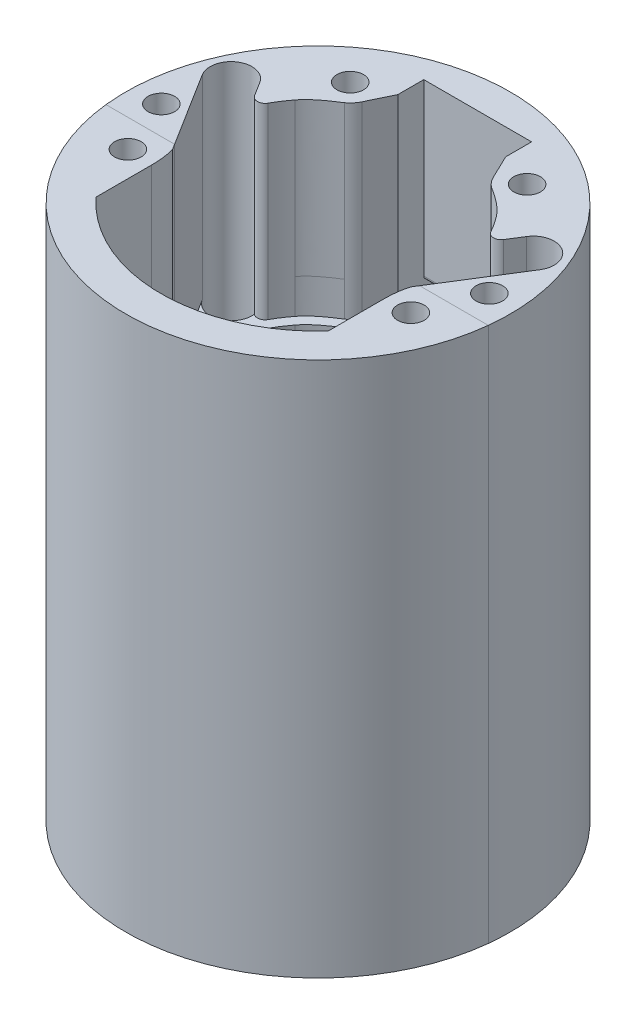
from build123d import *

# Parameters (mm, degrees)
SKETCH1_R              = 3.475
SKETCH1_R_2            = 5.461
BOSS_EXTRUDE2_DEPTH    = 100
SLOT_DEPTH             = 0.975
SKETCH2_W              = 28.2
SKETCH2_H              = 9.048762348
CUT_EXTRUDE1_DEPTH     = 3
FILLET1_R              = 1
LPATTERN1_COUNT        = 5
LPATTERN1_PITCH        = 20
FILLET1_OF_LPATTERN1_R = 1
SKETCH10_R             = 50.292
SKETCH10_R_2           = 3.475
SKETCH10_R_3           = 5.461
BOSS_EXTRUDE3_DEPTH    = 40
CUT_EXTRUDE2_START     = -50.975
CUT_EXTRUDE2_DEPTH     = 50.975
FILLET2_R              = 2


with BuildPart() as part:
    # Sketch1 → Boss-Extrude2 (new body)
    with BuildSketch(Plane(origin=(0, 0, 0), x_dir=(1, 0, 0), z_dir=(0, 1, 0))):
        with BuildLine():
            ThreePointArc((32.720459643, -38.19236553), (0, 50.292), (-32.720459643, -38.19236553))
            ThreePointArc((-32.720459643, -38.19236553), (0, -50.292), (32.720459643, -38.19236553))
        make_face()
        with Locations(Location((-37.000474826, -12.718618748, 0), (0, 0, 270))):
            Circle(SKETCH1_R, mode=Mode.SUBTRACT)
        with Locations(Location((-39.515350792, 16.778615909, 0), (0, 0, 270))):
            Circle(SKETCH1_R_2, mode=Mode.SUBTRACT)
        with Locations(Location((-23.129730363, 31.556520301, 0), (0, 0, 270))):
            Circle(SKETCH1_R, mode=Mode.SUBTRACT)
        with Locations(Location((37.000474826, -12.718618748, 0), (0, 0, 270))):
            Circle(SKETCH1_R, mode=Mode.SUBTRACT)
        with Locations(Location((39.515350792, 16.778615909, 0), (0, 0, 270))):
            Circle(SKETCH1_R_2, mode=Mode.SUBTRACT)
        with Locations(Location((23.129730363, 31.556520301, 0), (0, 0, 270))):
            Circle(SKETCH1_R, mode=Mode.SUBTRACT)
        with Locations(Location((-42.886820356, 1.924977859, 0), (0, 0, 270))):
            Circle(SKETCH1_R, mode=Mode.SUBTRACT)
        with Locations(Location((42.886820356, 1.924977859, 0), (0, 0, 270))):
            Circle(SKETCH1_R, mode=Mode.SUBTRACT)
        with BuildLine():
            Line((14.1, 34.984991814), (17.137442499, 28.672948531))
            ThreePointArc((17.137442499, 28.672948531), (18.015355552, 27.306147342), (19.198457256, 26.192977465))
            add(Edge.make_bspline(
                [(26.350445826, 20.302188629), (24.374677003, 22.988127573), (19.198457256, 26.192977465)],
                knots=[0, 0, 0, 1, 1, 1], degree=2))
            ThreePointArc((26.350445826, 20.302188629), (31.488556898, 10.723602139), (33.264468406, 0))
            add(Edge.make_bspline(
                [(30.348758021, -13.232808954), (30.348758021, -4.818714921), (33.264468406, -4.744134389), (33.264468406, 0)],
                knots=[0, 0, 0, 0, 1, 1, 1, 1], degree=3))
            Line((30.348758021, -13.232808954), (30.348758021, -27.696013052))
            ThreePointArc((30.348758021, -27.696013052), (0, -41.086691914), (-30.348758021, -27.696013052))
            Line((-30.348758021, -27.696013052), (-30.348758021, -13.232808954))
            add(Edge.make_bspline(
                [(-30.348758021, -13.232808954), (-30.348758021, -4.818714921), (-33.264468406, -4.744134389), (-33.264468406, 0)],
                knots=[0, 0, 0, 0, 1, 1, 1, 1], degree=3))
            ThreePointArc((-33.264468406, 0), (-31.488556898, 10.723602139), (-26.350445826, 20.302188629))
            add(Edge.make_bspline(
                [(-26.350445826, 20.302188629), (-24.374677003, 22.988127573), (-19.198457256, 26.192977465)],
                knots=[0, 0, 0, 1, 1, 1], degree=2))
            ThreePointArc((-19.198457256, 26.192977465), (-18.015355552, 27.306147342), (-17.137442499, 28.672948531))
            Line((-17.137442499, 28.672948531), (-14.1, 34.984991814))
            Line((-14.1, 34.984991814), (-14.1, 41.76))
            Line((-14.1, 41.76), (14.1, 41.76))
            Line((14.1, 41.76), (14.1, 34.984991814))
        make_face(mode=Mode.SUBTRACT)
    extrude(amount=BOSS_EXTRUDE2_DEPTH)

    # Sketch6 → slot (cut, symmetric)
    with BuildSketch(Plane(origin=(0, 10, 0), x_dir=(-1, 0, 0), z_dir=(0, -1, 0))):
        with BuildLine():
            Line((28.235055716, 33.155943022), (40.334074296, -5.463882427))
            Line((40.334074296, -5.463882427), (42.350474826, -5.463882427))
            Line((42.350474826, -5.463882427), (42.350474826, -12.718618748))
            ThreePointArc((42.350474826, -12.718618748), (41.836506168, -15.006696732), (40.393353009, -16.855148409))
            Line((40.393353009, -16.855148409), (31.491654075, -24.15652966))
            ThreePointArc((31.491654075, -24.15652966), (29.900450989, -25.057506014), (28.098775892, -25.37))
            Line((28.098775892, -25.37), (-28.098775892, -25.37))
            ThreePointArc((-28.098775892, -25.37), (-29.900450989, -25.057506014), (-31.491654075, -24.15652966))
            Line((-31.491654075, -24.15652966), (-40.393353009, -16.855148409))
            ThreePointArc((-40.393353009, -16.855148409), (-41.836506168, -15.006696732), (-42.350474826, -12.718618748))
            Line((-42.350474826, -12.718618748), (-42.350474826, -5.463882427))
            Line((-42.350474826, -5.463882427), (-40.334074296, -5.463882427))
            Line((-40.334074296, -5.463882427), (-28.235055716, 33.155943022))
            ThreePointArc((-28.235055716, 33.155943022), (-24.341289072, 36.767530328), (-19.253636812, 35.244120983))
            Line((-19.253636812, 35.244120983), (-13.047964359, 28.721243631))
            ThreePointArc((-13.047964359, 28.721243631), (-12.816725989, 28.560405037), (-12.540811932, 28.50373344))
            Line((-12.540811932, 28.50373344), (-10.657647051, 28.50373344))
            ThreePointArc((-10.657647051, 28.50373344), (-10.516225695, 28.562312083), (-10.457647051, 28.70373344))
            Line((-10.457647051, 28.70373344), (-10.457647051, 29.426019444))
            Line((-10.457647051, 29.426019444), (-10.457647051, 36.284264069))
            Line((-10.457647051, 36.284264069), (-9.78191112, 36.96))
            Line((-9.78191112, 36.96), (-3.333382982, 36.96))
            Line((-3.333382982, 36.96), (-2.657647051, 36.284264069))
            Line((-2.657647051, 36.284264069), (-2.657647051, 29.218375638))
            ThreePointArc((-2.657647051, 29.218375638), (-2.007647051, 28.607259567), (-1.357647051, 29.218375638))
            Line((-1.357647051, 29.218375638), (-1.357647051, 36.284264069))
            Line((-1.357647051, 36.284264069), (-0.68191112, 36.96))
            Line((-0.68191112, 36.96), (9.766617018, 36.96))
            Line((9.766617018, 36.96), (10.457647051, 36.268969967))
            Line((10.457647051, 36.268969967), (10.457647051, 29.426019444))
            Line((10.457647051, 29.426019444), (10.457647051, 28.70373344))
            ThreePointArc((10.457647051, 28.70373344), (10.516225695, 28.562312083), (10.657647051, 28.50373344))
            Line((10.657647051, 28.50373344), (12.540811932, 28.50373344))
            ThreePointArc((12.540811932, 28.50373344), (12.816725989, 28.560405037), (13.047964359, 28.721243631))
            Line((13.047964359, 28.721243631), (19.253636812, 35.244120983))
            ThreePointArc((19.253636812, 35.244120983), (24.341289072, 36.767530328), (28.235055716, 33.155943022))
        make_face()
    slot = extrude(amount=SLOT_DEPTH, both=True, mode=Mode.SUBTRACT)

    # Sketch2 → Cut-Extrude1 (cut)
    with BuildSketch(Plane.XY.offset(-41.76)):
        with Locations((0, 10)):
            Rectangle(SKETCH2_W, SKETCH2_H)
    cut_extrude1 = extrude(amount=-CUT_EXTRUDE1_DEPTH, mode=Mode.SUBTRACT)

    # Fillet1
    fillet1_edges = [part.edges().sort_by_distance(p)[0] for p in [
        (-14.1, 10, -44.76),
        (0, 14.524381174, -44.76),
        (14.1, 10, -44.76),
        (0, 5.475618826, -44.76),
        (0, 5.475618826, -41.76),
        (0, 14.524381174, -41.76),
    ]]
    fillet(fillet1_edges, radius=FILLET1_R)

    # LPattern1: slot, Cut-Extrude1 ×5
    with Locations(*[(0, i * LPATTERN1_PITCH, 0) for i in range(1, LPATTERN1_COUNT)]):
        add(slot, mode=Mode.SUBTRACT)
        add(cut_extrude1, mode=Mode.SUBTRACT)

    # Fillet1 of LPattern1
    fillet1_of_lpattern1_edges = [part.edges().sort_by_distance(p)[0] for p in [
        (-14.1, 30, -44.76),
        (0, 34.524381174, -44.76),
        (14.1, 30, -44.76),
        (0, 25.475618826, -44.76),
        (0, 25.475618826, -41.76),
        (0, 34.524381174, -41.76),
        (-14.1, 50, -44.76),
        (0, 54.524381174, -44.76),
        (14.1, 50, -44.76),
        (0, 45.475618826, -44.76),
        (0, 45.475618826, -41.76),
        (0, 54.524381174, -41.76),
        (-14.1, 70, -44.76),
        (0, 74.524381174, -44.76),
        (14.1, 70, -44.76),
        (0, 65.475618826, -44.76),
        (0, 65.475618826, -41.76),
        (0, 74.524381174, -41.76),
        (-14.1, 90, -44.76),
        (0, 94.524381174, -44.76),
        (14.1, 90, -44.76),
        (0, 85.475618826, -44.76),
        (0, 85.475618826, -41.76),
        (0, 94.524381174, -41.76),
    ]]
    fillet(fillet1_of_lpattern1_edges, radius=FILLET1_OF_LPATTERN1_R)

    # Sketch10 → Boss-Extrude3 (add)
    with BuildSketch(Plane(origin=(0, 100, 0), x_dir=(1, 0, 0), z_dir=(0, 1, 0))):
        with Locations(Location((0, 0, 0), (0, 0, 270))):
            Circle(SKETCH10_R)
        with Locations(Location((42.886820356, 1.924977859, 0), (0, 0, 270))):
            Circle(SKETCH10_R_2, mode=Mode.SUBTRACT)
        with Locations(Location((-42.886820356, 1.924977859, 0), (0, 0, 270))):
            Circle(SKETCH10_R_2, mode=Mode.SUBTRACT)
        with Locations(Location((39.515350792, 16.778615909, 0), (0, 0, 270))):
            Circle(SKETCH10_R_3, mode=Mode.SUBTRACT)
        with Locations(Location((-37.000474826, -12.718618748, 0), (0, 0, 90))):
            Circle(SKETCH10_R_2, mode=Mode.SUBTRACT)
        with Locations(Location((-39.515350792, 16.778615909, 0), (0, 0, 270))):
            Circle(SKETCH10_R_3, mode=Mode.SUBTRACT)
        with Locations(Location((-23.129730363, 31.556520301, 0), (0, 0, 90))):
            Circle(SKETCH10_R_2, mode=Mode.SUBTRACT)
        with Locations(Location((37.000474826, -12.718618748, 0), (0, 0, 90))):
            Circle(SKETCH10_R_2, mode=Mode.SUBTRACT)
        with Locations(Location((23.129730363, 31.556520301, 0), (0, 0, 90))):
            Circle(SKETCH10_R_2, mode=Mode.SUBTRACT)
        with BuildLine():
            Line((30.348758021, -27.696013052), (30.348758021, -13.232808954))
            add(Edge.make_bspline(
                [(30.348758021, -13.232808954), (30.348758021, -4.818714921), (33.264468406, -4.744134389), (33.264468406, 0)],
                knots=[0, 0, 0, 0, 1, 1, 1, 1], degree=3))
            ThreePointArc((33.264468406, 0), (31.488556898, 10.723602139), (26.350445826, 20.302188629))
            add(Edge.make_bspline(
                [(26.350445826, 20.302188629), (24.374677003, 22.988127573), (19.198457256, 26.192977465)],
                knots=[0, 0, 0, 1, 1, 1], degree=2))
            ThreePointArc((19.198457256, 26.192977465), (18.015355552, 27.306147342), (17.137442499, 28.672948531))
            Line((17.137442499, 28.672948531), (14.1, 34.984991814))
            Line((14.1, 34.984991814), (14.1, 41.76))
            Line((14.1, 41.76), (-14.1, 41.76))
            Line((-14.1, 41.76), (-14.1, 34.984991814))
            Line((-14.1, 34.984991814), (-17.137442499, 28.672948531))
            ThreePointArc((-17.137442499, 28.672948531), (-18.015355545, 27.306147348), (-19.198457242, 26.192977474))
            add(Edge.make_bspline(
                [(-19.198457242, 26.192977474), (-24.374677, 22.988127577), (-26.350445826, 20.302188629)],
                knots=[0, 0, 0, 1, 1, 1], degree=2))
            ThreePointArc((-26.350445826, 20.302188629), (-31.488556898, 10.723602139), (-33.264468406, 0))
            add(Edge.make_bspline(
                [(-33.264468406, 0), (-33.264468406, -4.744134389), (-30.348758021, -4.818714921), (-30.348758021, -13.232808954)],
                knots=[0, 0, 0, 0, 1, 1, 1, 1], degree=3))
            Line((-30.348758021, -13.232808954), (-30.348758021, -27.696013052))
            ThreePointArc((-30.348758021, -27.696013052), (0, -41.086691914), (30.348758021, -27.696013052))
        make_face(mode=Mode.SUBTRACT)
    extrude(amount=BOSS_EXTRUDE3_DEPTH)

    # Sketch11 → Cut-Extrude2 (cut)
    with BuildSketch(Plane(origin=(0, 140, 0), x_dir=(1, 0, 0), z_dir=(0, 1, 0)).offset(CUT_EXTRUDE2_START)):
        Polygon((-44.14499129, 13.882247517), (-30.086366648, -8.58947196), (-20.827085651, -2.796735177), (-34.885710293, 19.6749843), align=None)
    cut_extrude2 = extrude(amount=CUT_EXTRUDE2_DEPTH, mode=Mode.SUBTRACT)

    # Mirror2: Cut-Extrude2 across plane
    add(cut_extrude2.mirror(Plane(origin=(0, 0, 0), x_dir=(0, 0, 1), z_dir=(1, 0, 0))), mode=Mode.SUBTRACT)

    # Fillet2
    fillet2_edges = [part.edges().sort_by_distance(p)[0] for p in [
        (-30.655617718, 115.4875, -12.913479804),
        (30.655617718, 120, -12.913479804),
    ]]
    fillet(fillet2_edges, radius=FILLET2_R)


with BuildPart() as body_2:
    # Split1: the piece on the far side of the plane
    add(part.part)
    split(bisect_by=Plane.XY.offset(5.463882427), keep=Keep.BOTTOM)


with BuildPart() as part_1:
    add(part.part)

    # Split1
    split(bisect_by=Plane.XY.offset(5.463882427), keep=Keep.TOP)


solid = Compound([body_2.part, part_1.part])
